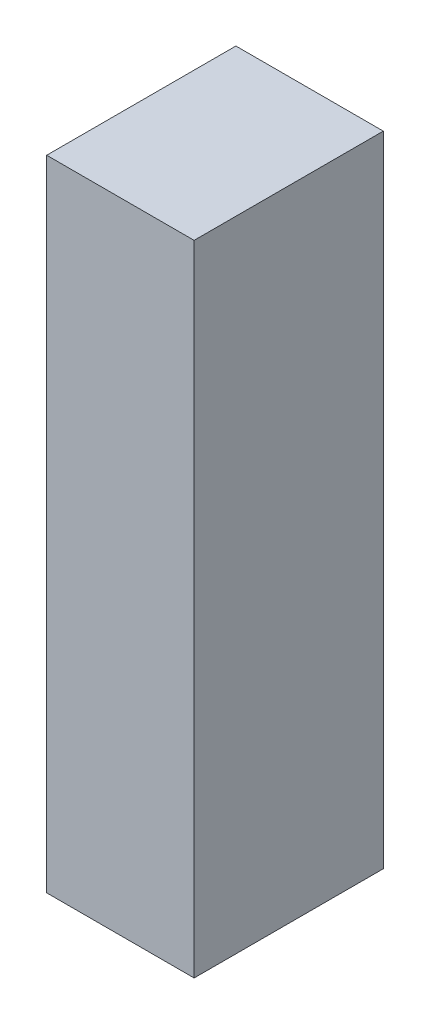
from build123d import *

# Parameters (mm, degrees)
CROQUIS1_W              = 300
CROQUIS1_H              = 385
SALIENTE_EXTRUIR1_DEPTH = 1300


with BuildPart() as part:
    # Croquis1 → Saliente-Extruir1 (new body)
    with BuildSketch(Plane(origin=(0, 0, 0), x_dir=(1, 0, 0), z_dir=(0, 1, 0))):
        Rectangle(CROQUIS1_W, CROQUIS1_H)
    extrude(amount=SALIENTE_EXTRUIR1_DEPTH)


solid = part.part
